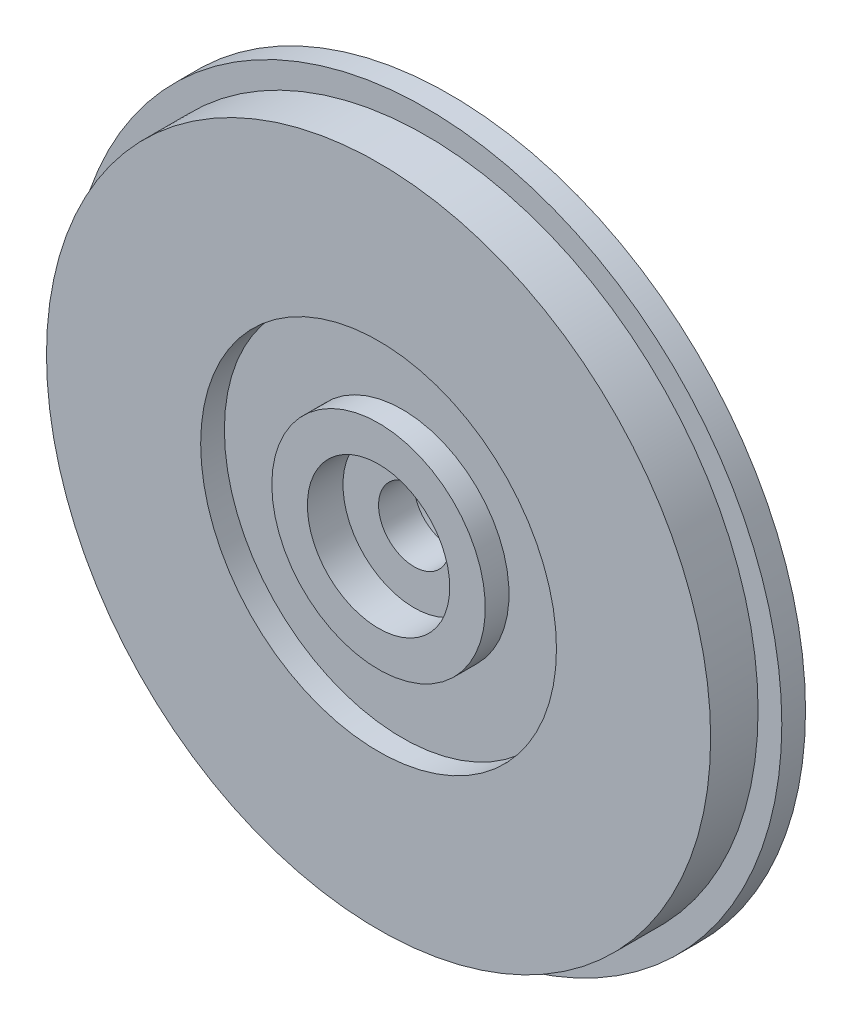
from build123d import *

# Parameters (mm, degrees)
SKETCH3_R           = 3
CUT_EXTRUDE1_DEPTH  = 1.5
SKETCH4_R           = 1.5
CUT_EXTRUDE2_DEPTH  = 2.5
SKETCH5_R           = 5
SKETCH5_R_2         = 4
EXTRUDE_THIN1_DEPTH = 2


with BuildPart() as part:
    # Sketch1 → Revolve1 (revolve)
    with BuildSketch(Plane(origin=(0, 0, 0), x_dir=(1, 0, 0), z_dir=(0, 1, 0))):
        Polygon((0, -1), (4.5, -1), (4.5, 0), (7.5, 0), (7.5, -1), (14, -1), (14, 1), (15, 1), (15, 2), (0, 2), align=None)
    revolve(axis=Axis((0, 0, -2), (0, 0, 1)))

    # Sketch3 → Cut-Extrude1 (cut)
    with BuildSketch(Plane.XY.offset(1)):
        Circle(SKETCH3_R)
    extrude(amount=-CUT_EXTRUDE1_DEPTH, mode=Mode.SUBTRACT)

    # Sketch4 → Cut-Extrude2 (cut, through all)
    with BuildSketch(Plane.XY.offset(-0.5)):
        Circle(SKETCH4_R)
    extrude(amount=-CUT_EXTRUDE2_DEPTH, mode=Mode.SUBTRACT)

    # Sketch5 → Extrude-Thin1 (add)
    with BuildSketch(Plane(origin=(0, 0, -2), x_dir=(-1, 0, 0), z_dir=(0, 0, -1))):
        Circle(SKETCH5_R)
        Circle(SKETCH5_R_2, mode=Mode.SUBTRACT)
    extrude(amount=EXTRUDE_THIN1_DEPTH)


solid = part.part
